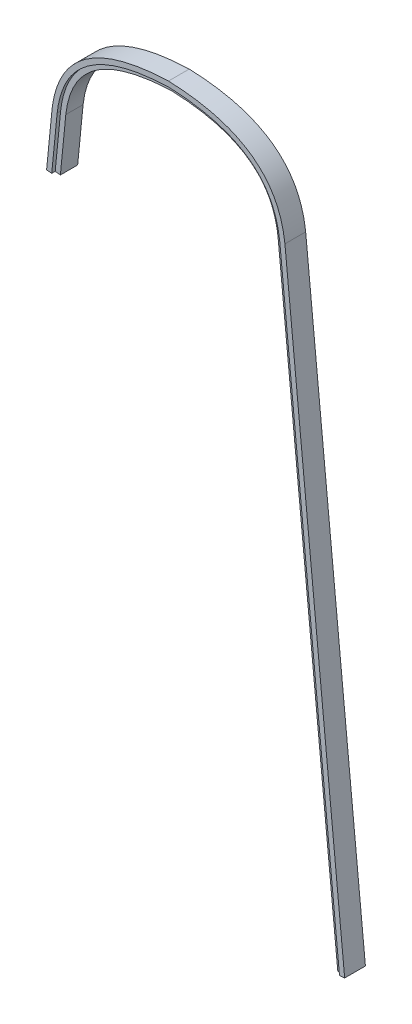
from build123d import *

# Parameters (mm, degrees)
BOSS_EXTRUDE1_DEPTH     = 19.05
CUT_EXTRUDE1_DEPTH      = 1.0000001
CUT_EXTRUDE1_DEPTH_BACK = 3.175


with BuildPart() as part:
    # Sketch1 → Boss-Extrude1 (new body)
    with BuildSketch(Plane.XY):
        with BuildLine():
            Line((152.224173193, 179.795336584), (97.403993572, 735.828587024))
            add(Edge.make_bspline(
                [(0, 803.26908628), (0.979817658, 803.233925105), (2.950075123, 803.151909058), (6.800362849, 802.946009068), (11.504912112, 802.608232022), (16.957304332, 802.075979486), (23.975792063, 801.198424891), (32.273128008, 799.790052384), (41.46699497, 797.614109593), (49.89784204, 794.967332344), (60.129456963, 790.832450746), (71.050790712, 784.572420078), (79.648241417, 776.932392043), (85.274313562, 769.943199813), (88.89525226, 764.228265264), (91.933130485, 758.00316425), (93.979934001, 752.359286407), (95.321414001, 747.554999291), (96.177362738, 743.805316844), (96.764020616, 740.553537606), (97.155379667, 737.881968465), (97.326205951, 736.51096636), (97.403993572, 735.828587024)],
                knots=[0.000508173, 0.000508173, 0.000508173, 0.000508173, 0.016098161, 0.031688149, 0.062868125, 0.094048101, 0.125228077, 0.187588029, 0.249947981, 0.312307933, 0.374667885, 0.499387789, 0.624107693, 0.686467645, 0.748827597, 0.811187549, 0.873547501, 0.904727477, 0.935907453, 0.967087429, 0.982677417, 0.998267405, 0.998267405, 0.998267405, 0.998267405], degree=3))
            add(Edge.make_bspline(
                [(-97.403993572, 735.828587024), (-97.326205951, 736.51096636), (-97.155379667, 737.881968465), (-96.764020616, 740.553537606), (-96.177362738, 743.805316844), (-95.321414001, 747.554999291), (-93.979934001, 752.359286407), (-91.933130485, 758.00316425), (-88.89525226, 764.228265264), (-85.274313562, 769.943199813), (-79.648241417, 776.932392043), (-71.050790712, 784.572420078), (-60.129456963, 790.832450746), (-49.89784204, 794.967332344), (-41.46699497, 797.614109593), (-32.273128008, 799.790052384), (-23.975792063, 801.198424891), (-16.957304332, 802.075979486), (-11.504912112, 802.608232022), (-6.800362849, 802.946009068), (-2.950075123, 803.151909058), (-0.979817658, 803.233925105), (0, 803.26908628)],
                knots=[0.000508173, 0.000508173, 0.000508173, 0.000508173, 0.016098161, 0.031688149, 0.062868125, 0.094048101, 0.125228077, 0.187588029, 0.249947981, 0.312307933, 0.374667885, 0.499387789, 0.624107693, 0.686467645, 0.748827597, 0.811187549, 0.873547501, 0.904727477, 0.935907453, 0.967087429, 0.982677417, 0.998267405, 0.998267405, 0.998267405, 0.998267405], degree=3))
            Line((-97.403993572, 735.828587024), (-102.381323889, 685.344236665))
            Line((-102.381323889, 685.344236665), (-111.860365766, 686.278790089))
            Line((-111.860365766, 686.278790089), (-106.876080835, 736.833680097))
            add(Edge.make_bspline(
                [(-106.876080835, 736.833680097), (-98.655564568, 809.385111394), (0, 812.8)],
                knots=[0, 0, 0, 1, 1, 1], degree=2))
            add(Edge.make_bspline(
                [(106.876080835, 736.833680097), (98.655564568, 809.385111394), (0, 812.8)],
                knots=[0, 0, 0, 1, 1, 1], degree=2))
            Line((106.876080835, 736.833680097), (161.70321507, 180.729890008))
            Line((161.70321507, 180.729890008), (152.224173193, 179.795336584))
        make_face()
    extrude(amount=BOSS_EXTRUDE1_DEPTH)

    # Sketch2 → Cut-Extrude1 (cut, two sides)
    with BuildSketch(Plane.XY.offset(19.05)) as cut_extrude1_sk:
        with BuildLine():
            Line((152.224173193, 179.795336584), (156.976332854, 180.263859367))
            Line((156.976332854, 180.263859367), (102.152626971, 736.332876181))
            add(Edge.make_bspline(
                [(102.152626971, 736.332876181), (101.496352881, 742.108028156), (100.395212832, 747.499058108), (97.327555266, 757.533990297), (95.361854235, 762.178148206), (90.572537126, 770.764926128), (87.748995317, 774.708742888), (81.215321126, 781.943258676), (77.504081602, 785.23458987), (69.146529075, 791.181342383), (64.499476138, 793.836180237), (54.235830034, 798.495292835), (48.619370919, 800.498919802), (30.298797632, 805.498551699), (16.122322173, 807.479219325), (2e-09, 808.047304319)],
                knots=[0, 0, 0, 0, 0.125, 0.125, 0.25, 0.25, 0.375, 0.375, 0.5, 0.5, 0.625, 0.625, 0.75, 0.75, 1, 1, 1, 1], degree=3))
            add(Edge.make_bspline(
                [(2e-09, 808.047304319), (-16.122322169, 807.479219325), (-30.298797629, 805.498551699), (-48.619370917, 800.498919802), (-54.235830032, 798.495292835), (-64.499476136, 793.836180238), (-69.146529074, 791.181342384), (-77.504081601, 785.234589871), (-81.215321126, 781.943258677), (-87.748995317, 774.708742888), (-90.572537125, 770.764926128), (-95.361854235, 762.178148207), (-97.327555266, 757.533990298), (-100.395212832, 747.499058108), (-101.496352881, 742.108028156), (-102.152626971, 736.332876181)],
                knots=[0, 0, 0, 0, 0.25, 0.25, 0.375, 0.375, 0.5, 0.5, 0.625, 0.625, 0.75, 0.75, 0.875, 0.875, 1, 1, 1, 1], degree=3))
            Line((-102.152626971, 736.332876181), (-107.13348355, 685.812759448))
            Line((-107.13348355, 685.812759448), (-102.381323889, 685.344236665))
            Line((-102.381323889, 685.344236665), (-97.403993572, 735.828587024))
            add(Edge.make_bspline(
                [(-97.403993572, 735.828587024), (-97.326205951, 736.51096636), (-97.155379667, 737.881968465), (-96.764020616, 740.553537606), (-96.177362738, 743.805316844), (-95.321414001, 747.554999291), (-93.979934001, 752.359286407), (-91.933130485, 758.00316425), (-88.89525226, 764.228265264), (-85.274313562, 769.943199813), (-79.648241417, 776.932392043), (-71.050790712, 784.572420078), (-60.129456963, 790.832450746), (-49.89784204, 794.967332344), (-41.46699497, 797.614109593), (-32.273128008, 799.790052384), (-23.975792063, 801.198424891), (-16.957304332, 802.075979486), (-11.504912112, 802.608232022), (-6.800362849, 802.946009068), (-2.950075123, 803.151909058), (-0.979817658, 803.233925105), (0, 803.26908628)],
                knots=[0.000508173, 0.000508173, 0.000508173, 0.000508173, 0.016098161, 0.031688149, 0.062868125, 0.094048101, 0.125228077, 0.187588029, 0.249947981, 0.312307933, 0.374667885, 0.499387789, 0.624107693, 0.686467645, 0.748827597, 0.811187549, 0.873547501, 0.904727477, 0.935907453, 0.967087429, 0.982677417, 0.998267405, 0.998267405, 0.998267405, 0.998267405], degree=3))
            add(Edge.make_bspline(
                [(0, 803.26908628), (0.979817658, 803.233925105), (2.950075123, 803.151909058), (6.800362849, 802.946009068), (11.504912112, 802.608232022), (16.957304332, 802.075979486), (23.975792063, 801.198424891), (32.273128008, 799.790052384), (41.46699497, 797.614109593), (49.89784204, 794.967332344), (60.129456963, 790.832450746), (71.050790712, 784.572420078), (79.648241417, 776.932392043), (85.274313562, 769.943199813), (88.89525226, 764.228265264), (91.933130485, 758.00316425), (93.979934001, 752.359286407), (95.321414001, 747.554999291), (96.177362738, 743.805316844), (96.764020616, 740.553537606), (97.155379667, 737.881968465), (97.326205951, 736.51096636), (97.403993572, 735.828587024)],
                knots=[0.000508173, 0.000508173, 0.000508173, 0.000508173, 0.016098161, 0.031688149, 0.062868125, 0.094048101, 0.125228077, 0.187588029, 0.249947981, 0.312307933, 0.374667885, 0.499387789, 0.624107693, 0.686467645, 0.748827597, 0.811187549, 0.873547501, 0.904727477, 0.935907453, 0.967087429, 0.982677417, 0.998267405, 0.998267405, 0.998267405, 0.998267405], degree=3))
            Line((97.403993572, 735.828587024), (152.224173193, 179.795336584))
        make_face()
    extrude(amount=CUT_EXTRUDE1_DEPTH, mode=Mode.SUBTRACT)
    extrude(cut_extrude1_sk.sketch, amount=-CUT_EXTRUDE1_DEPTH_BACK, mode=Mode.SUBTRACT)


solid = part.part
